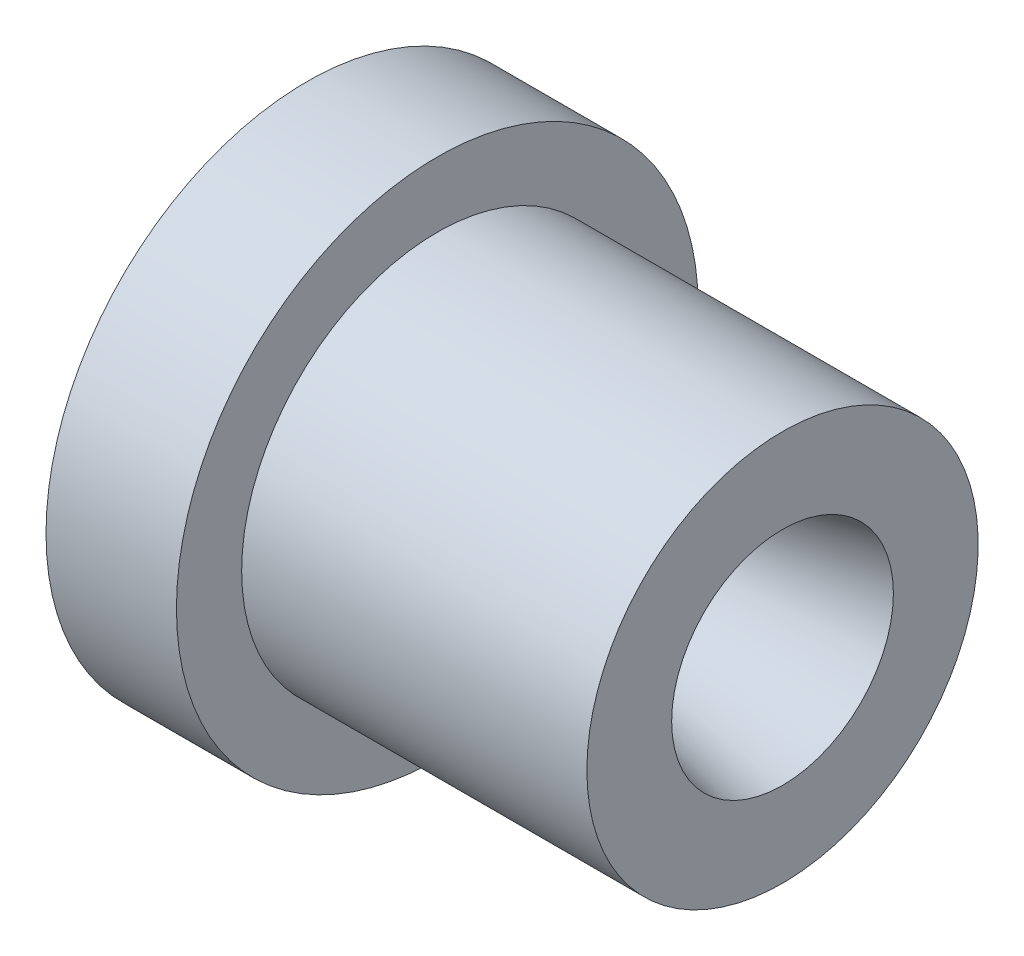
from build123d import *


with BuildPart() as part:
    # Sketch4 → Revolve1 (revolve)
    with BuildSketch(Plane.XY):
        Polygon((-10, 20), (0, 20), (0, 15), (26.466205383, 15), (26.466205383, 8.5), (10, 5), (0, 5), (-10, 15), align=None)
    revolve(axis=Axis((-30.301204819, 0, 0), (1, 0, 0)))


solid = part.part
